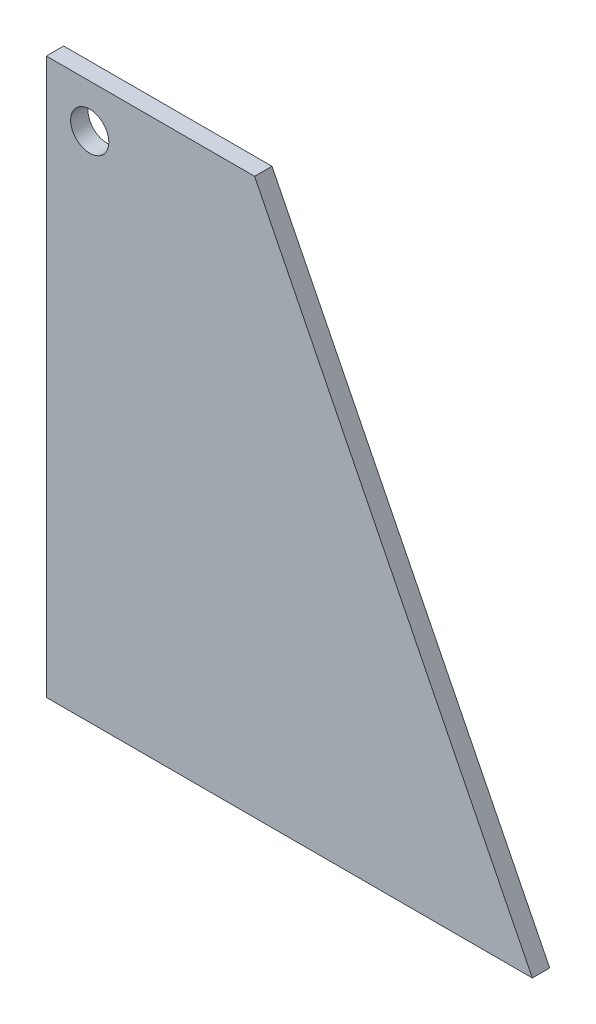
from build123d import *

# Parameters (mm, degrees)
SKETCH1_R           = 6.985
BOSS_EXTRUDE1_DEPTH = 3.175


with BuildPart() as part:
    # Sketch1 → Boss-Extrude1 (new body, symmetric)
    with BuildSketch(Plane.XY):
        Polygon((-88.9, 101.6), (-88.9, -101.6), (88.9, -101.6), (-12.7, 101.6), align=None)
        with Locations((-73.025, 85.725)):
            Circle(SKETCH1_R, mode=Mode.SUBTRACT)
    extrude(amount=BOSS_EXTRUDE1_DEPTH, both=True)


solid = part.part
